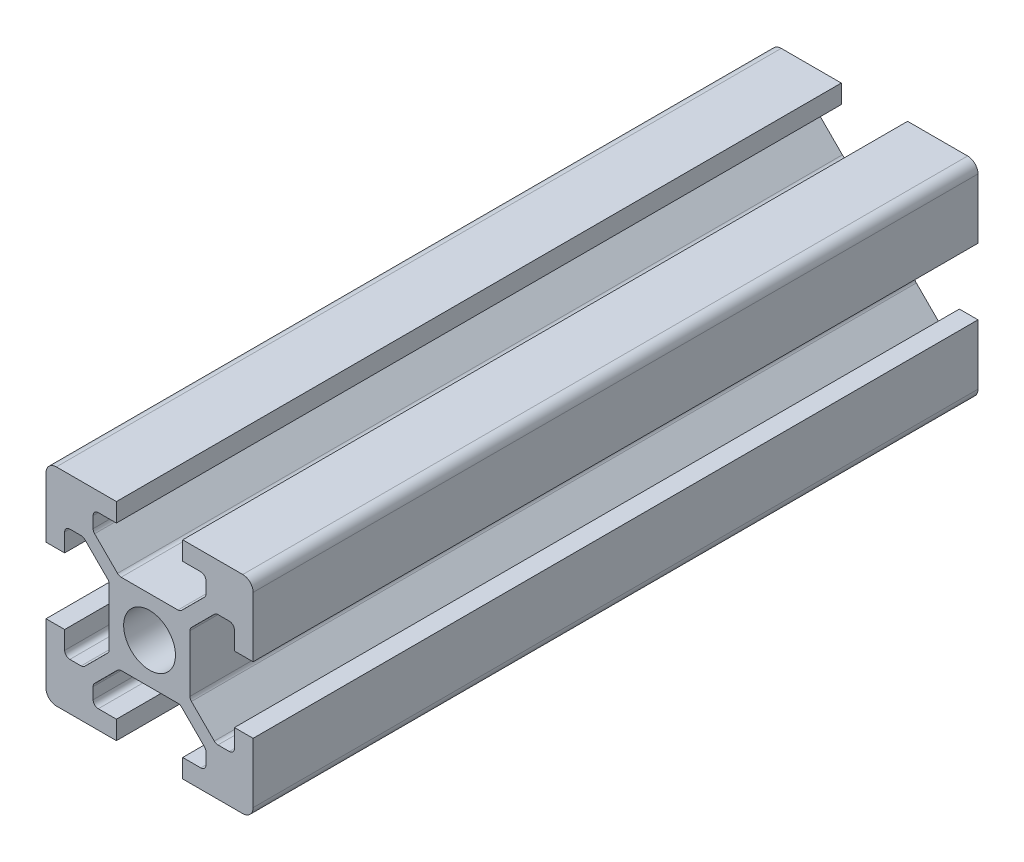
from build123d import *

# Parameters (mm, degrees)
SKETCH1_R           = 2.5
BOSS_EXTRUDE1_DEPTH = 70
FILLET1_R           = 1
FILLET2_R           = 0.5
FILLET3_R           = 0.5
FILLET4_R           = 0.5
FILLET5_R           = 0.5


with BuildPart() as part:
    # Sketch1 → Boss-Extrude1 (new body)
    with BuildSketch(Plane.XY):
        Polygon((13.2, 0), (13.2, 1.8), (15.45, 1.8), (15.45, 3.6), (12.95, 6.1), (7.05, 6.1), (4.55, 3.6), (4.55, 1.8), (6.8, 1.8), (6.8, 0), (0, 0), (0, 6.8), (1.8, 6.8), (1.8, 4.55), (3.6, 4.55), (6.1, 7.05), (6.1, 12.95), (3.6, 15.45), (1.8, 15.45), (1.8, 13.2), (0, 13.2), (0, 20), (6.8, 20), (6.8, 18.2), (4.55, 18.2), (4.55, 16.4), (7.05, 13.9), (12.95, 13.9), (15.45, 16.4), (15.45, 18.2), (13.2, 18.2), (13.2, 20), (20, 20), (20, 13.2), (18.2, 13.2), (18.2, 15.45), (16.4, 15.45), (13.9, 12.95), (13.9, 7.05), (16.4, 4.55), (18.2, 4.55), (18.2, 6.8), (20, 6.8), (20, 0), align=None)
        with Locations((10, 10)):
            Circle(SKETCH1_R, mode=Mode.SUBTRACT)
    extrude(amount=BOSS_EXTRUDE1_DEPTH)

    # Fillet1
    fillet1_edges = [part.edges().sort_by_distance(p)[0] for p in [
        (0, 0, 35),
        (0, 20, 35),
        (20, 20, 35),
        (20, 0, 35),
    ]]
    fillet(fillet1_edges, radius=FILLET1_R)

    # Fillet2
    fillet2_edges = [part.edges().sort_by_distance(p)[0] for p in [
        (4.55, 18.2, 35),
        (4.55, 16.4, 35),
        (7.05, 13.9, 35),
        (12.95, 13.9, 35),
        (15.45, 16.4, 35),
        (15.45, 18.2, 35),
    ]]
    fillet(fillet2_edges, radius=FILLET2_R)

    # Fillet3
    fillet3_edges = [part.edges().sort_by_distance(p)[0] for p in [
        (18.2, 15.45, 35),
        (16.4, 15.45, 35),
        (13.9, 12.95, 35),
        (13.9, 7.05, 35),
        (16.4, 4.55, 35),
        (18.2, 4.55, 35),
    ]]
    fillet(fillet3_edges, radius=FILLET3_R)

    # Fillet4
    fillet4_edges = [part.edges().sort_by_distance(p)[0] for p in [
        (1.8, 4.55, 35),
        (3.6, 4.55, 35),
        (6.1, 7.05, 35),
        (6.1, 12.95, 35),
        (3.6, 15.45, 35),
        (1.8, 15.45, 35),
    ]]
    fillet(fillet4_edges, radius=FILLET4_R)

    # Fillet5
    fillet5_edges = [part.edges().sort_by_distance(p)[0] for p in [
        (15.45, 1.8, 35),
        (15.45, 3.6, 35),
        (12.95, 6.1, 35),
        (7.05, 6.1, 35),
        (4.55, 3.6, 35),
        (4.55, 1.8, 35),
    ]]
    fillet(fillet5_edges, radius=FILLET5_R)


solid = part.part
